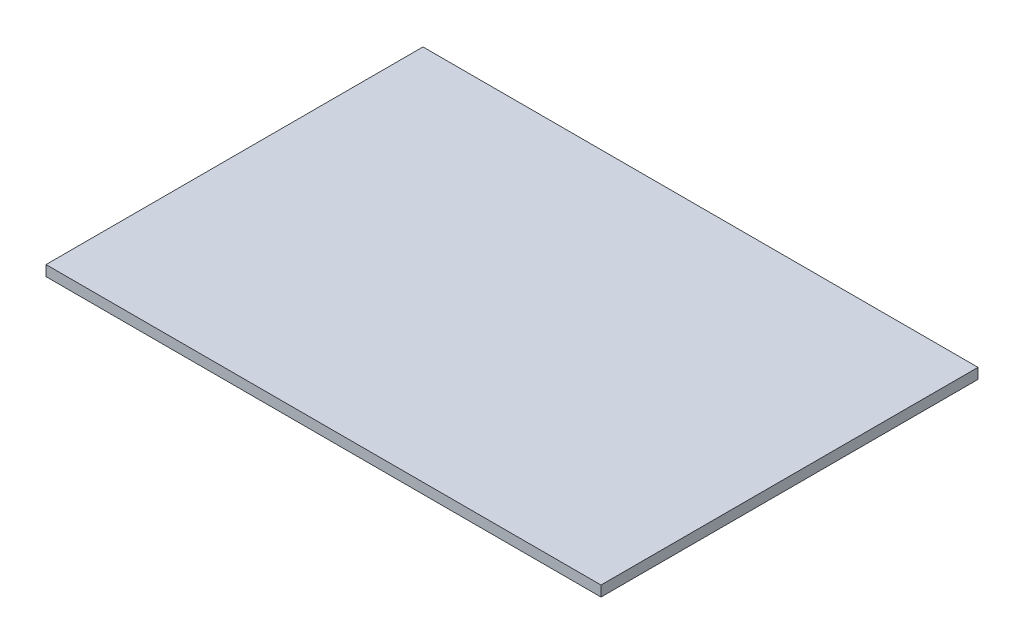
from build123d import *

# Parameters (mm, degrees)
SKETCH_1_W      = 530
SKETCH_1_H      = 360
EXTRUDE_1_DEPTH = 10


with BuildPart() as part:
    # Эскиз1 → Бобышка-Вытянуть1 (new body)
    with BuildSketch(Plane(origin=(0, 0, 0), x_dir=(1, 0, 0), z_dir=(0, 1, 0))):
        Rectangle(SKETCH_1_W, SKETCH_1_H)
    extrude(amount=EXTRUDE_1_DEPTH)


solid = part.part
